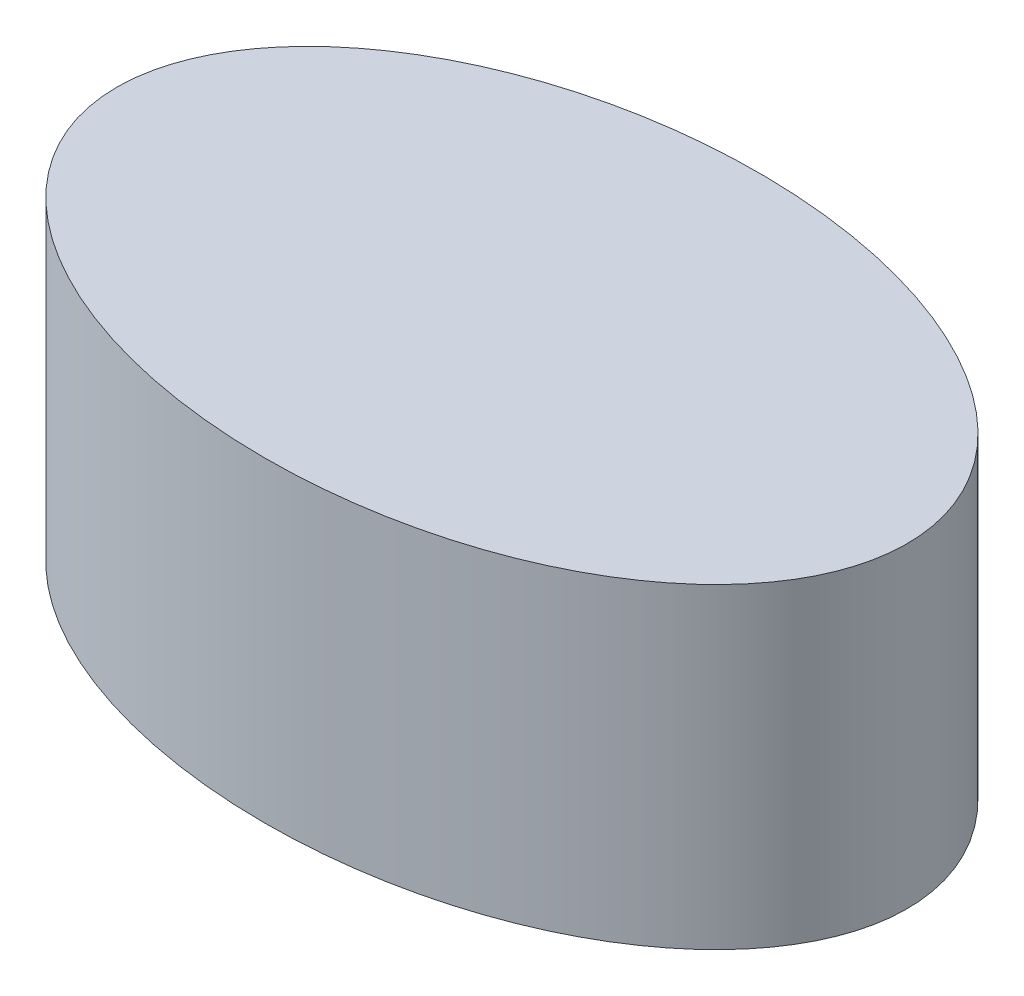
from build123d import *

# Parameters (mm, degrees)
LEATHER_BELT_RX     = 200
LEATHER_BELT_RY     = 125
BOSS_EXTRUDE1_DEPTH = 160


with BuildPart() as part:
    # Leather_belt → Boss-Extrude1 (new body)
    with BuildSketch(Plane(origin=(0, 0, 0), x_dir=(1, 0, 0), z_dir=(0, 1, 0))):
        with Locations(Location((0, 0), (0, 0, 180))):
            Ellipse(LEATHER_BELT_RX, LEATHER_BELT_RY)
    extrude(amount=BOSS_EXTRUDE1_DEPTH)


solid = part.part
